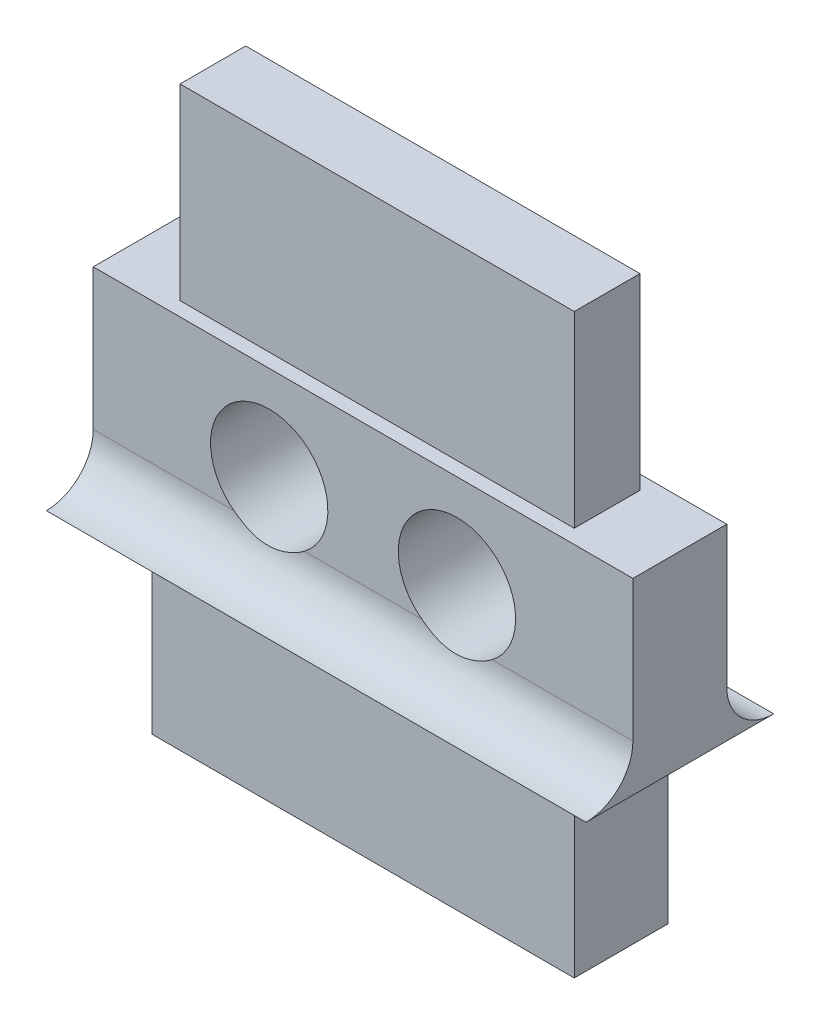
from build123d import *

# Parameters (mm, degrees)
MODEL_R                 = 1.25
BOSS_EXTRUDE1_DEPTH     = 2
BOSS_EXTRUDE2_DEPTH     = 11.50072
SKETCH2_R               = 1.25
CUT_EXTRUDE1_DEPTH      = 2
CUT_EXTRUDE1_DEPTH_BACK = 4
SKETCH3_W               = 9.00072
SKETCH3_H               = 2
SKETCH3_W_2             = 8.40072
SKETCH3_H_2             = 1.4
CUT_EXTRUDE2_DEPTH      = 4


with BuildPart() as part:
    # Model → Boss-Extrude1 (new body)
    with BuildSketch(Plane.XY):
        Polygon((1.25, 4), (0, 4), (0, 8), (1.25, 8), (1.25, 12), (10.25072, 12), (10.25072, 8), (11.50072, 8), (11.50072, 4), (10.25072, 4), (10.25072, 0), (1.25, 0), align=None)
        with Locations((7.75072, 6)):
            Circle(MODEL_R, mode=Mode.SUBTRACT)
        with Locations((3.75, 6)):
            Circle(MODEL_R, mode=Mode.SUBTRACT)
    extrude(amount=BOSS_EXTRUDE1_DEPTH)

    # Sketch1 → Boss-Extrude2 (add)
    with BuildSketch(Plane.ZY):
        with BuildLine():
            Line((2, 4), (2, 5))
            ThreePointArc((2, 5), (2.292893219, 4.292893219), (3, 4))
            Line((3, 4), (2, 4))
        make_face()
        with BuildLine():
            Line((0, 4), (-1, 4))
            ThreePointArc((-1, 4), (-0.292893219, 4.292893219), (0, 5))
            Line((0, 5), (0, 4))
        make_face()
    extrude(amount=-BOSS_EXTRUDE2_DEPTH)

    # Sketch2 → Cut-Extrude1 (cut, two sides)
    with BuildSketch(Plane.XY.offset(2)) as cut_extrude1_sk:
        with Locations((3.75, 6)):
            Circle(SKETCH2_R)
        with Locations((7.75072, 6)):
            Circle(SKETCH2_R)
    extrude(amount=CUT_EXTRUDE1_DEPTH, mode=Mode.SUBTRACT)
    extrude(cut_extrude1_sk.sketch, amount=-CUT_EXTRUDE1_DEPTH_BACK, mode=Mode.SUBTRACT)

    # Sketch3 → Cut-Extrude2 (cut)
    with BuildSketch(Plane(origin=(0, 12, 0), x_dir=(1, 0, 0), z_dir=(0, 1, 0))):
        with Locations((5.75036, -1)):
            Rectangle(SKETCH3_W, SKETCH3_H)
        with Locations((5.75036, -1)):
            Rectangle(SKETCH3_W_2, SKETCH3_H_2, mode=Mode.SUBTRACT)
    extrude(amount=-CUT_EXTRUDE2_DEPTH, mode=Mode.SUBTRACT)


solid = part.part
